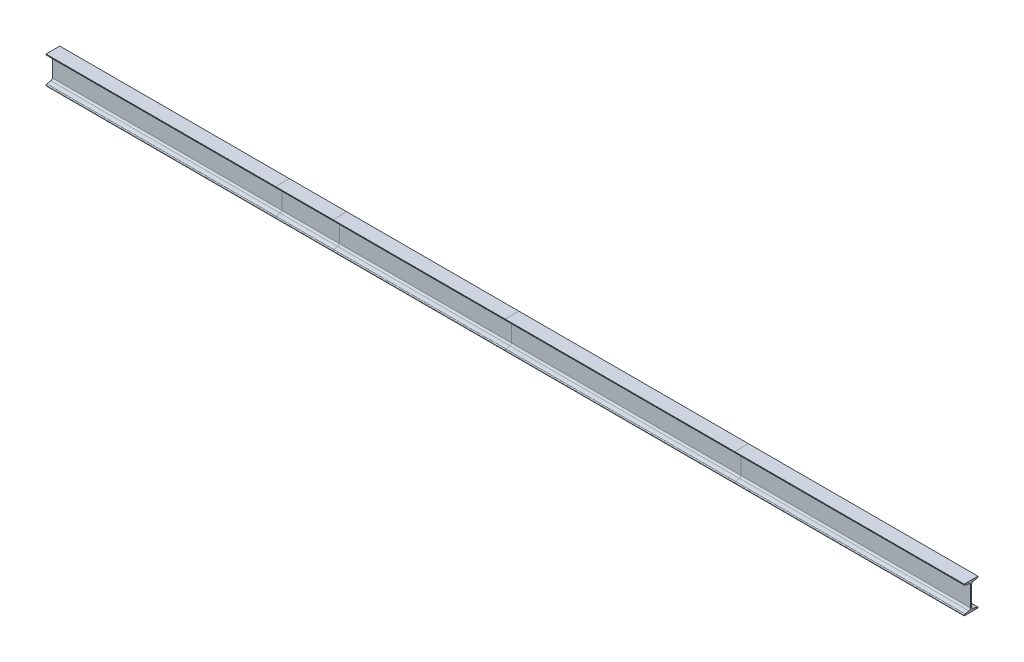
from build123d import *

# Parameters (mm, degrees)
SB_BEAM_CONFIGURED_120_X_12_1_DEPTH   = 1000
SB_BEAM_CONFIGURED_120_X_12_1_2_DEPTH = 250
SB_BEAM_CONFIGURED_120_X_12_1_3_DEPTH = 750
SB_BEAM_CONFIGURED_120_X_12_1_4_DEPTH = 1000
SB_BEAM_CONFIGURED_120_X_12_1_5_DEPTH = 1000


with BuildPart() as part:
    # Sketch11 → Sb beam - configured 120 X 12(1) (new body)
    with BuildSketch(Plane(origin=(0, 0, 0), x_dir=(0, 0, 1), z_dir=(1, 0, 0))):
        with BuildLine():
            Line((-30, -60), (-30, -58.080070835))
            ThreePointArc((-30, -58.080070835), (-29.052095223, -55.494589303), (-26.657642624, -54.134502919))
            Line((-26.657642624, -54.134502919), (-9.184714752, -51.222135832))
            ThreePointArc((-9.184714752, -51.222135832), (-4.395809555, -48.501963064), (-2.5, -43.331))
            Line((-2.5, -43.331), (-2.5, 43.331))
            ThreePointArc((-2.5, 43.331), (-4.395809555, 48.501963064), (-9.184714752, 51.222135832))
            Line((-9.184714752, 51.222135832), (-26.657642624, 54.134502919))
            ThreePointArc((-26.657642624, 54.134502919), (-29.052095223, 55.494589303), (-30, 58.080070835))
            Line((-30, 58.080070835), (-30, 60))
            Line((-30, 60), (30, 60))
            Line((30, 60), (30, 58.080070835))
            ThreePointArc((30, 58.080070835), (29.052095223, 55.494589303), (26.657642624, 54.134502919))
            Line((26.657642624, 54.134502919), (9.184714752, 51.222135832))
            ThreePointArc((9.184714752, 51.222135832), (4.395809555, 48.501963064), (2.5, 43.331))
            Line((2.5, 43.331), (2.5, -43.331))
            ThreePointArc((2.5, -43.331), (4.395809555, -48.501963064), (9.184714752, -51.222135832))
            Line((9.184714752, -51.222135832), (26.657642624, -54.134502919))
            ThreePointArc((26.657642624, -54.134502919), (29.052095223, -55.494589303), (30, -58.080070835))
            Line((30, -58.080070835), (30, -60))
            Line((30, -60), (-30, -60))
        make_face()
    extrude(amount=SB_BEAM_CONFIGURED_120_X_12_1_DEPTH)


with BuildPart() as body_2:
    # Sketch11 on segment 2 (carried to segment 2) → Sb beam - configured 120 X 12_1 2 (new body)
    with BuildSketch(Plane(origin=(1000, 0, 0), x_dir=(0, 0, 1), z_dir=(1, 0, 0))):
        with BuildLine():
            Line((-30, -60), (-30, -58.080070835))
            ThreePointArc((-30, -58.080070835), (-29.052095223, -55.494589303), (-26.657642624, -54.134502919))
            Line((-26.657642624, -54.134502919), (-9.184714752, -51.222135832))
            ThreePointArc((-9.184714752, -51.222135832), (-4.395809555, -48.501963064), (-2.5, -43.331))
            Line((-2.5, -43.331), (-2.5, 43.331))
            ThreePointArc((-2.5, 43.331), (-4.395809555, 48.501963064), (-9.184714752, 51.222135832))
            Line((-9.184714752, 51.222135832), (-26.657642624, 54.134502919))
            ThreePointArc((-26.657642624, 54.134502919), (-29.052095223, 55.494589303), (-30, 58.080070835))
            Line((-30, 58.080070835), (-30, 60))
            Line((-30, 60), (30, 60))
            Line((30, 60), (30, 58.080070835))
            ThreePointArc((30, 58.080070835), (29.052095223, 55.494589303), (26.657642624, 54.134502919))
            Line((26.657642624, 54.134502919), (9.184714752, 51.222135832))
            ThreePointArc((9.184714752, 51.222135832), (4.395809555, 48.501963064), (2.5, 43.331))
            Line((2.5, 43.331), (2.5, -43.331))
            ThreePointArc((2.5, -43.331), (4.395809555, -48.501963064), (9.184714752, -51.222135832))
            Line((9.184714752, -51.222135832), (26.657642624, -54.134502919))
            ThreePointArc((26.657642624, -54.134502919), (29.052095223, -55.494589303), (30, -58.080070835))
            Line((30, -58.080070835), (30, -60))
            Line((30, -60), (-30, -60))
        make_face()
    extrude(amount=SB_BEAM_CONFIGURED_120_X_12_1_2_DEPTH)


with BuildPart() as body_3:
    # Sketch11 on segment 3 (carried to segment 3) → Sb beam - configured 120 X 12_1 3 (new body)
    with BuildSketch(Plane(origin=(1250, 0, 0), x_dir=(0, 0, 1), z_dir=(1, 0, 0))):
        with BuildLine():
            Line((-30, -60), (-30, -58.080070835))
            ThreePointArc((-30, -58.080070835), (-29.052095223, -55.494589303), (-26.657642624, -54.134502919))
            Line((-26.657642624, -54.134502919), (-9.184714752, -51.222135832))
            ThreePointArc((-9.184714752, -51.222135832), (-4.395809555, -48.501963064), (-2.5, -43.331))
            Line((-2.5, -43.331), (-2.5, 43.331))
            ThreePointArc((-2.5, 43.331), (-4.395809555, 48.501963064), (-9.184714752, 51.222135832))
            Line((-9.184714752, 51.222135832), (-26.657642624, 54.134502919))
            ThreePointArc((-26.657642624, 54.134502919), (-29.052095223, 55.494589303), (-30, 58.080070835))
            Line((-30, 58.080070835), (-30, 60))
            Line((-30, 60), (30, 60))
            Line((30, 60), (30, 58.080070835))
            ThreePointArc((30, 58.080070835), (29.052095223, 55.494589303), (26.657642624, 54.134502919))
            Line((26.657642624, 54.134502919), (9.184714752, 51.222135832))
            ThreePointArc((9.184714752, 51.222135832), (4.395809555, 48.501963064), (2.5, 43.331))
            Line((2.5, 43.331), (2.5, -43.331))
            ThreePointArc((2.5, -43.331), (4.395809555, -48.501963064), (9.184714752, -51.222135832))
            Line((9.184714752, -51.222135832), (26.657642624, -54.134502919))
            ThreePointArc((26.657642624, -54.134502919), (29.052095223, -55.494589303), (30, -58.080070835))
            Line((30, -58.080070835), (30, -60))
            Line((30, -60), (-30, -60))
        make_face()
    extrude(amount=SB_BEAM_CONFIGURED_120_X_12_1_3_DEPTH)


with BuildPart() as body_4:
    # Sketch11 on segment 4 (carried to segment 4) → Sb beam - configured 120 X 12_1 4 (new body)
    with BuildSketch(Plane(origin=(2000, 0, 0), x_dir=(0, 0, 1), z_dir=(1, 0, 0))):
        with BuildLine():
            Line((-30, -60), (-30, -58.080070835))
            ThreePointArc((-30, -58.080070835), (-29.052095223, -55.494589303), (-26.657642624, -54.134502919))
            Line((-26.657642624, -54.134502919), (-9.184714752, -51.222135832))
            ThreePointArc((-9.184714752, -51.222135832), (-4.395809555, -48.501963064), (-2.5, -43.331))
            Line((-2.5, -43.331), (-2.5, 43.331))
            ThreePointArc((-2.5, 43.331), (-4.395809555, 48.501963064), (-9.184714752, 51.222135832))
            Line((-9.184714752, 51.222135832), (-26.657642624, 54.134502919))
            ThreePointArc((-26.657642624, 54.134502919), (-29.052095223, 55.494589303), (-30, 58.080070835))
            Line((-30, 58.080070835), (-30, 60))
            Line((-30, 60), (30, 60))
            Line((30, 60), (30, 58.080070835))
            ThreePointArc((30, 58.080070835), (29.052095223, 55.494589303), (26.657642624, 54.134502919))
            Line((26.657642624, 54.134502919), (9.184714752, 51.222135832))
            ThreePointArc((9.184714752, 51.222135832), (4.395809555, 48.501963064), (2.5, 43.331))
            Line((2.5, 43.331), (2.5, -43.331))
            ThreePointArc((2.5, -43.331), (4.395809555, -48.501963064), (9.184714752, -51.222135832))
            Line((9.184714752, -51.222135832), (26.657642624, -54.134502919))
            ThreePointArc((26.657642624, -54.134502919), (29.052095223, -55.494589303), (30, -58.080070835))
            Line((30, -58.080070835), (30, -60))
            Line((30, -60), (-30, -60))
        make_face()
    extrude(amount=SB_BEAM_CONFIGURED_120_X_12_1_4_DEPTH)


with BuildPart() as body_5:
    # Sketch11 on segment 5 (carried to segment 5) → Sb beam - configured 120 X 12_1 5 (new body)
    with BuildSketch(Plane(origin=(3000, 0, 0), x_dir=(0, 0, 1), z_dir=(1, 0, 0))):
        with BuildLine():
            Line((-30, -60), (-30, -58.080070835))
            ThreePointArc((-30, -58.080070835), (-29.052095223, -55.494589303), (-26.657642624, -54.134502919))
            Line((-26.657642624, -54.134502919), (-9.184714752, -51.222135832))
            ThreePointArc((-9.184714752, -51.222135832), (-4.395809555, -48.501963064), (-2.5, -43.331))
            Line((-2.5, -43.331), (-2.5, 43.331))
            ThreePointArc((-2.5, 43.331), (-4.395809555, 48.501963064), (-9.184714752, 51.222135832))
            Line((-9.184714752, 51.222135832), (-26.657642624, 54.134502919))
            ThreePointArc((-26.657642624, 54.134502919), (-29.052095223, 55.494589303), (-30, 58.080070835))
            Line((-30, 58.080070835), (-30, 60))
            Line((-30, 60), (30, 60))
            Line((30, 60), (30, 58.080070835))
            ThreePointArc((30, 58.080070835), (29.052095223, 55.494589303), (26.657642624, 54.134502919))
            Line((26.657642624, 54.134502919), (9.184714752, 51.222135832))
            ThreePointArc((9.184714752, 51.222135832), (4.395809555, 48.501963064), (2.5, 43.331))
            Line((2.5, 43.331), (2.5, -43.331))
            ThreePointArc((2.5, -43.331), (4.395809555, -48.501963064), (9.184714752, -51.222135832))
            Line((9.184714752, -51.222135832), (26.657642624, -54.134502919))
            ThreePointArc((26.657642624, -54.134502919), (29.052095223, -55.494589303), (30, -58.080070835))
            Line((30, -58.080070835), (30, -60))
            Line((30, -60), (-30, -60))
        make_face()
    extrude(amount=SB_BEAM_CONFIGURED_120_X_12_1_5_DEPTH)


solid = Compound([part.part, body_2.part, body_3.part, body_4.part, body_5.part])
